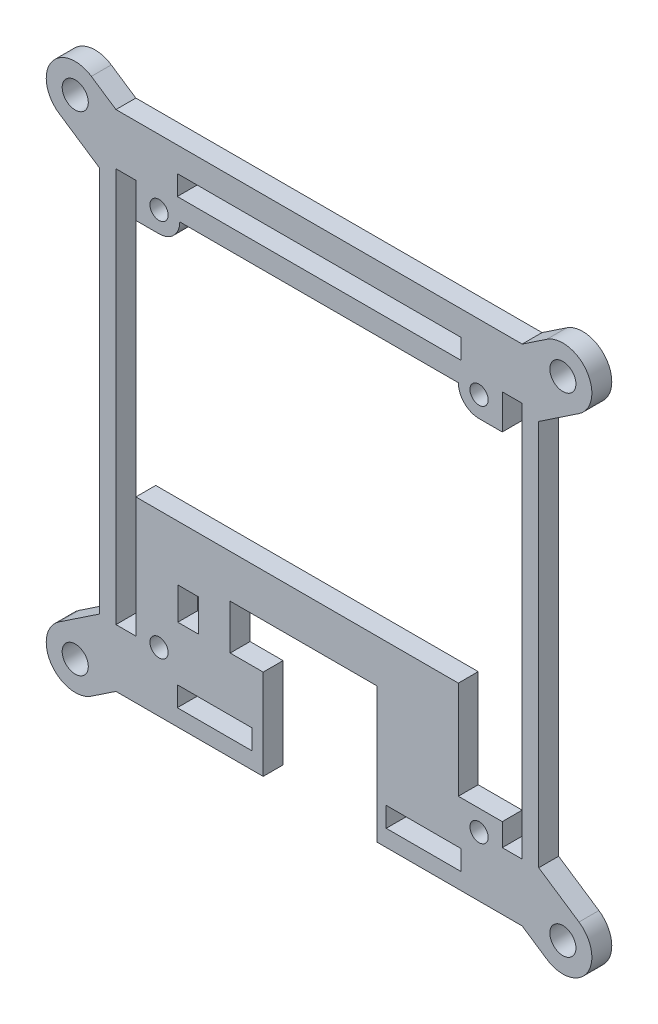
from build123d import *

# Parameters (mm, degrees)
SKETCH1_R           = 1.397
SKETCH1_W           = 3.175
SKETCH1_H           = 4.953
SKETCH1_W_2         = 11.43
SKETCH1_H_2         = 3.048
SKETCH1_W_3         = 43.434
BOSS_EXTRUDE1_DEPTH = 3.048
FILLET1_R           = 2.54
SKETCH2_R           = 2
BOSS_EXTRUDE2_DEPTH = 3.048


with BuildPart() as part:
    # Sketch1 → Boss-Extrude1 (new body)
    with BuildSketch(Plane.XY):
        Polygon((-3.7846, 71.611586257), (-3.7846, -5.588), (21.3106, -5.588), (21.3106, -4.3434), (21.3106, 8.255), (16.256, 8.255), (16.256, 15.1384), (38.7858, 15.1384), (38.7858, -4.3434), (38.7858, -5.588), (63.5254, -5.588), (63.5254, 71.611586257), align=None)
        with Locations((5.3594, 3.556)):
            Circle(SKETCH1_R, mode=Mode.SUBTRACT)
        with Locations((9.8171, 10.8077)):
            Rectangle(SKETCH1_W, SKETCH1_H, mode=Mode.SUBTRACT)
        with Locations((13.8684, -1.524)):
            Rectangle(SKETCH1_W_2, SKETCH1_H_2, mode=Mode.SUBTRACT)
        with Locations((45.8724, -1.524)):
            Rectangle(SKETCH1_W_2, SKETCH1_H_2, mode=Mode.SUBTRACT)
        with Locations((54.3814, 3.556)):
            Circle(SKETCH1_R, mode=Mode.SUBTRACT)
        with BuildLine():
            Line((-1.2446, 63.754), (1.8034, 63.754))
            Line((1.8034, 63.754), (1.8034, 58.42))
            Line((1.8034, 58.42), (5.3594, 58.42))
            ThreePointArc((5.3594, 58.42), (7.60446403, 59.34993597), (8.5344, 61.595))
            Line((8.5344, 61.595), (51.2064, 61.595))
            ThreePointArc((51.2064, 61.595), (52.13633597, 59.34993597), (54.3814, 58.42))
            Line((54.3814, 58.42), (57.9374, 58.42))
            Line((57.9374, 58.42), (57.9374, 63.754))
            Line((57.9374, 63.754), (60.9854, 63.754))
            Line((60.9854, 63.754), (60.9854, 3.2766))
            Line((60.9854, 3.2766), (57.9374, 3.2766))
            Line((57.9374, 3.2766), (57.9374, 6.731))
            Line((57.9374, 6.731), (51.2064, 6.731))
            Line((51.2064, 6.731), (51.2064, 21.7424))
            Line((51.2064, 21.7424), (1.8034, 21.7424))
            Line((1.8034, 21.7424), (1.8034, 3.2766))
            Line((1.8034, 3.2766), (-1.2446, 3.2766))
            Line((-1.2446, 3.2766), (-1.2446, 63.754))
        make_face(mode=Mode.SUBTRACT)
        with Locations((5.3594, 61.595)):
            Circle(SKETCH1_R, mode=Mode.SUBTRACT)
        with Locations((29.8704, 66.294)):
            Rectangle(SKETCH1_W_3, SKETCH1_H_2, mode=Mode.SUBTRACT)
        with Locations((54.3814, 61.595)):
            Circle(SKETCH1_R, mode=Mode.SUBTRACT)
    extrude(amount=BOSS_EXTRUDE1_DEPTH)

    # Fillet1
    fillet1_edges = [part.edges().sort_by_distance(p)[0] for p in [
        (-3.7846, -5.588, 1.524),
        (-3.7846, 71.611586257, 1.524),
        (63.5254, 71.611586257, 1.524),
        (63.5254, -5.588, 1.524),
    ]]
    fillet(fillet1_edges, radius=FILLET1_R)

    # Sketch2 → Boss-Extrude2 (add)
    with BuildSketch(Plane.XY.offset(3.048)):
        with BuildLine():
            ThreePointArc((-3.055036152, 70.853136408), (-2.226043482, 71.414313021), (-1.2446, 71.611586257))
            Line((-1.2446, 71.611586257), (-5.010493887, 74.127944533))
            ThreePointArc((-5.010493887, 74.127944533), (-11.175901405, 72.901649241), (-9.949606113, 66.736241724))
            Line((-9.949606113, 66.736241724), (-3.7846, 62.616804315))
            Line((-3.7846, 62.616804315), (-3.7846, 67.961936393))
            ThreePointArc((-3.7846, 67.961936393), (-3.170149461, 69.344535157), (-3.055036152, 70.853136408))
        make_face()
        with Locations((-7.48005, 70.432093129)):
            Circle(SKETCH2_R, mode=Mode.SUBTRACT)
        with BuildLine():
            ThreePointArc((-1.2446, -5.588), (-2.226043482, -5.390726764), (-3.055036152, -4.829550151))
            ThreePointArc((-3.055036152, -4.829550151), (-3.170149461, -3.3209489), (-3.7846, -1.938350136))
            Line((-3.7846, -1.938350136), (-3.7846, 3.406781942))
            Line((-3.7846, 3.406781942), (-9.949606113, -0.712655467))
            ThreePointArc((-9.949606113, -0.712655467), (-11.175901405, -6.878062984), (-5.010493887, -8.104358276))
            Line((-5.010493887, -8.104358276), (-1.2446, -5.588))
        make_face()
        with Locations((-7.48005, -4.408506871)):
            Circle(SKETCH2_R, mode=Mode.SUBTRACT)
        with BuildLine():
            ThreePointArc((64.751293887, -8.104358276), (70.916701405, -6.878062984), (69.690406113, -0.712655467))
            Line((69.690406113, -0.712655467), (63.5254, 3.406781942))
            Line((63.5254, 3.406781942), (63.5254, -1.938350136))
            ThreePointArc((63.5254, -1.938350136), (62.910949461, -3.3209489), (62.795836152, -4.829550151))
            ThreePointArc((62.795836152, -4.829550151), (61.966843482, -5.390726764), (60.9854, -5.588))
            Line((60.9854, -5.588), (64.751293887, -8.104358276))
        make_face()
        with Locations((67.22085, -4.408506871)):
            Circle(SKETCH2_R, mode=Mode.SUBTRACT)
        with BuildLine():
            ThreePointArc((60.9854, 71.611586257), (61.966843482, 71.414313021), (62.795836152, 70.853136408))
            ThreePointArc((62.795836152, 70.853136408), (62.910949461, 69.344535157), (63.5254, 67.961936393))
            Line((63.5254, 67.961936393), (63.5254, 62.616804315))
            Line((63.5254, 62.616804315), (69.690406113, 66.736241724))
            ThreePointArc((69.690406113, 66.736241724), (70.916701405, 72.901649241), (64.751293887, 74.127944533))
            Line((64.751293887, 74.127944533), (60.9854, 71.611586257))
        make_face()
        with Locations((67.22085, 70.432093129)):
            Circle(SKETCH2_R, mode=Mode.SUBTRACT)
    extrude(amount=-BOSS_EXTRUDE2_DEPTH)


solid = part.part
